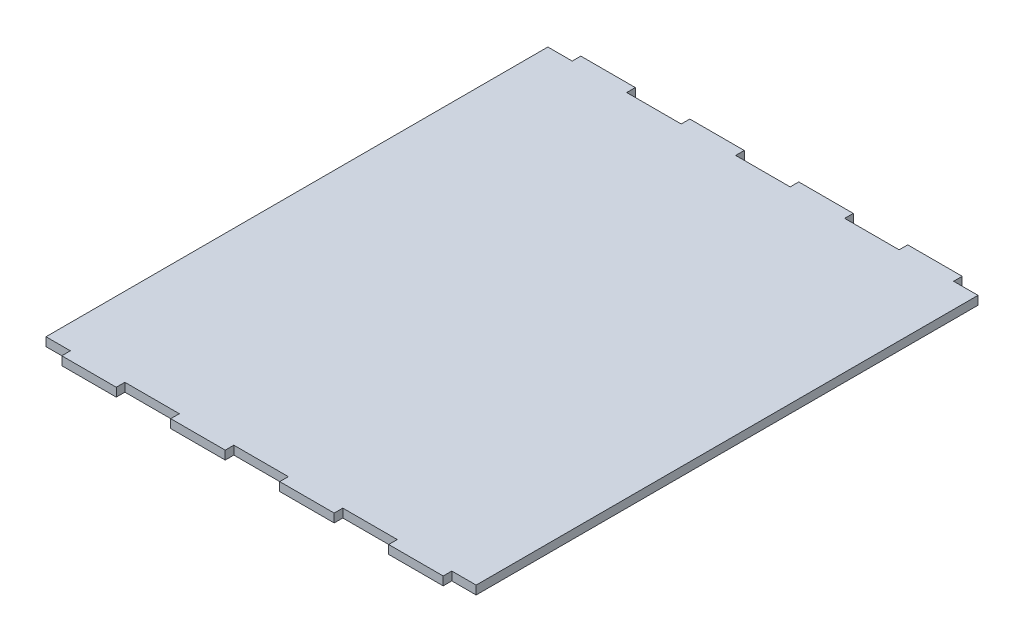
from build123d import *

# Parameters (mm, degrees)
BOSS_EXTRUDE1_DEPTH = 3


with BuildPart() as part:
    # Sketch1 → Boss-Extrude1 (new body)
    with BuildSketch(Plane(origin=(0, 0, 0), x_dir=(1, 0, 0), z_dir=(0, 1, 0))):
        Polygon((46.5, 181), (65.5, 181), (65.5, 178), (84.5, 178), (84.5, 181), (103.5, 181), (103.5, 178), (122.5, 178), (122.5, 181), (141.5, 181), (141.5, 178), (150, 178), (150, 3), (141.5, 3), (141.5, 0), (122.5, 0), (122.5, 3), (103.5, 3), (103.5, 0), (84.5, 0), (84.5, 3), (65.5, 3), (65.5, 0), (46.5, 0), (46.5, 3), (27.5, 3), (27.5, 0), (8.5, 0), (8.5, 3), (0, 3), (0, 178), (8.5, 178), (8.5, 181), (27.5, 181), (27.5, 178), (46.5, 178), align=None)
    extrude(amount=BOSS_EXTRUDE1_DEPTH)


solid = part.part
